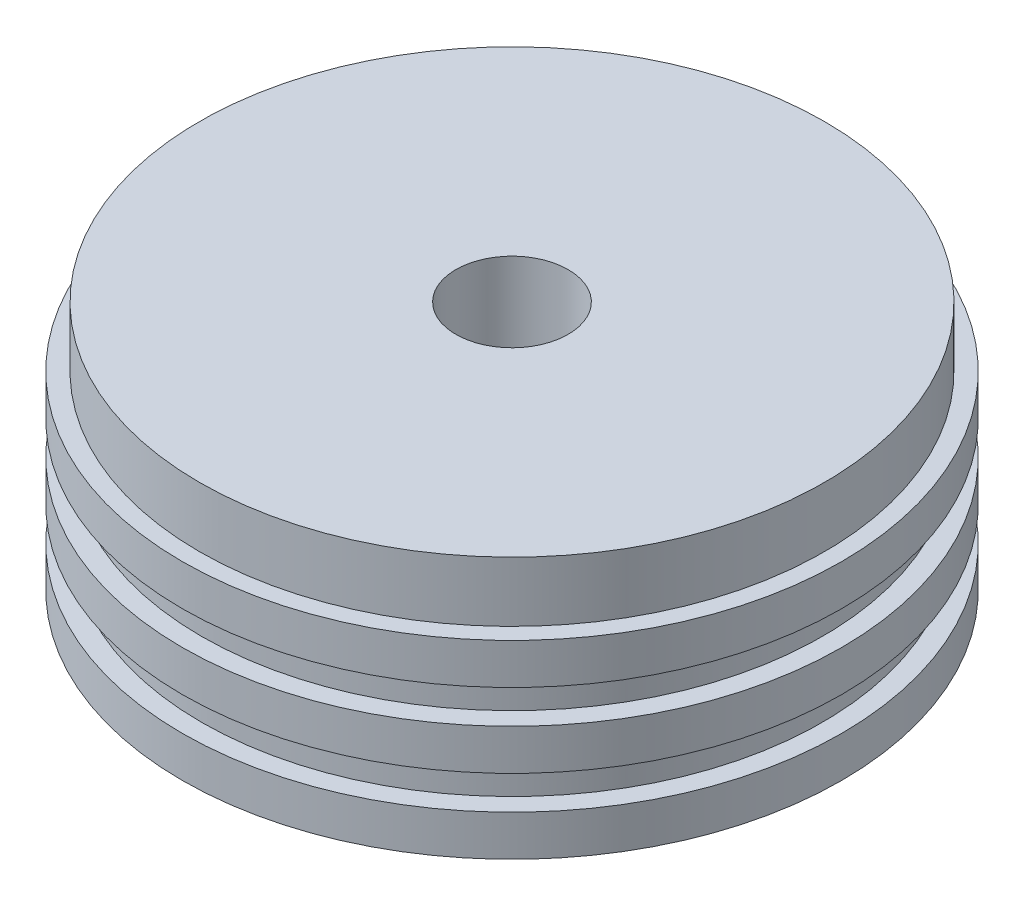
from build123d import *

# Parameters (mm, degrees)
F_1_4_18_NPSM_TAPPED_HOLE1_D = 11.8872


with BuildPart() as part:
    # Sketch8 → Revolve1 (revolve)
    with BuildSketch(Plane.XY):
        Polygon((0, 0), (0, 26.416), (-33.0835, 26.416), (-33.0835, 20.066), (-34.8996, 20.066), (-34.8996, 15.748), (-32.8676, 15.748), (-32.8676, 12.192), (-34.8996, 12.192), (-34.8996, 7.874), (-32.8676, 7.874), (-32.8676, 4.318), (-34.8996, 4.318), (-34.8996, 0), align=None)
    revolve(axis=Axis((0, 0, 0), (0, 1, 0)))

    # 1/4-18 NPSM Tapped Hole1 (through all)
    with Locations(Plane(origin=(0, 0, 0), x_dir=(-1, 0, 0), z_dir=(0, -1, 0))):
        with Locations((0, 0)):
            Hole(F_1_4_18_NPSM_TAPPED_HOLE1_D / 2)


solid = part.part
